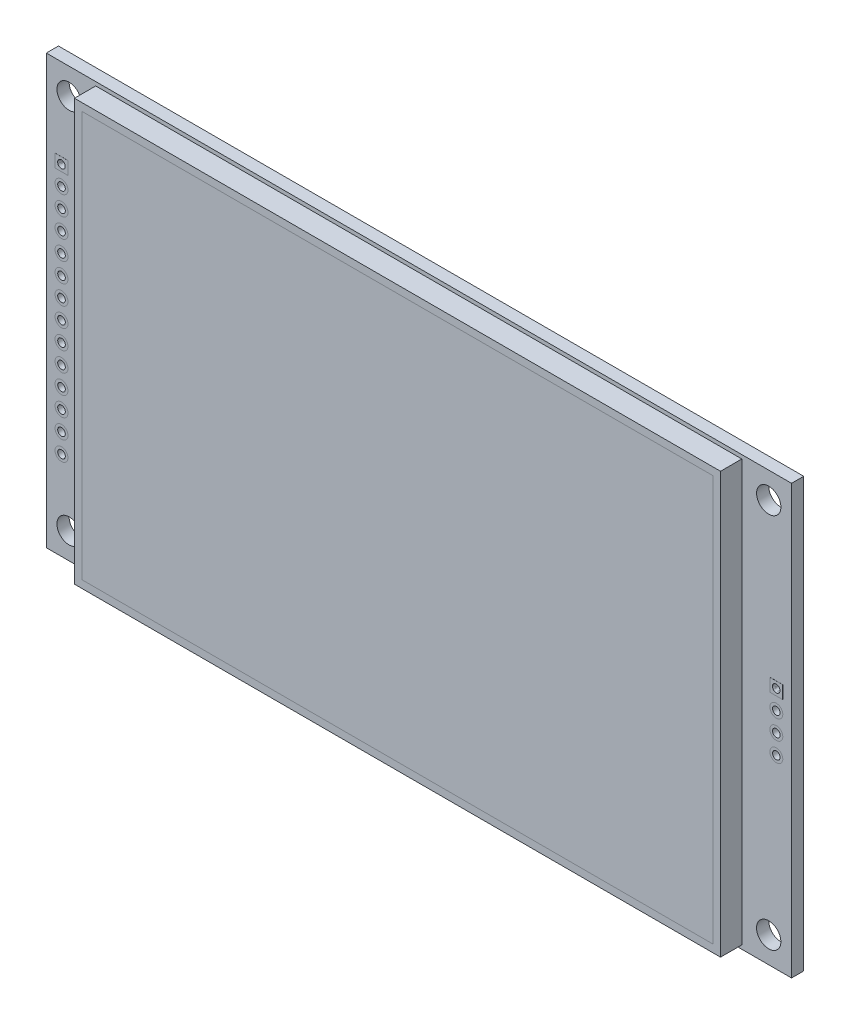
from build123d import *

# Parameters (mm, degrees)
SKETCH2_W               = 98
SKETCH2_H               = 56.34
BOSS_EXTRUDE1_DEPTH     = 0.8
SKETCH3_R               = 1.6
CUT_EXTRUDE1_DEPTH      = 2.6
MIRROR2_COPY_1_SKETCH_R = 1.6
MIRROR2_COPY_1_DEPTH    = 2.6
SKETCH5_W               = 84.96
SKETCH5_H               = 55.34
SKETCH5_W_2             = 82.96
SKETCH5_H_2             = 53.34
BOSS_EXTRUDE2_DEPTH     = 2.8
SKETCH6_W               = 82.96
SKETCH6_H               = 53.34
BOSS_EXTRUDE3_DEPTH     = 2.8
SKETCH9_R               = 0.85
CUT_EXTRUDE2_DEPTH      = 2.6
SKETCH10_R              = 0.85
SKETCH10_R_2            = 0.5
BOSS_EXTRUDE4_DEPTH     = 1.6
BOSS_EXTRUDE4_2_DEPTH   = 1.6
BOSS_EXTRUDE4_3_DEPTH   = 1.6
BOSS_EXTRUDE4_4_DEPTH   = 1.6
BOSS_EXTRUDE4_5_DEPTH   = 1.6
BOSS_EXTRUDE4_6_DEPTH   = 1.6
BOSS_EXTRUDE4_7_DEPTH   = 1.6
BOSS_EXTRUDE4_8_DEPTH   = 1.6
BOSS_EXTRUDE4_9_DEPTH   = 1.6
BOSS_EXTRUDE4_10_DEPTH  = 1.6
BOSS_EXTRUDE4_11_DEPTH  = 1.6
BOSS_EXTRUDE4_12_DEPTH  = 1.6
BOSS_EXTRUDE4_13_DEPTH  = 1.6
BOSS_EXTRUDE4_14_DEPTH  = 1.6
SKETCH11_R              = 0.85
CUT_EXTRUDE3_DEPTH      = 2.6
SKETCH12_R              = 0.85
SKETCH12_R_2            = 0.5
BOSS_EXTRUDE5_DEPTH     = 1.6
BOSS_EXTRUDE5_2_DEPTH   = 1.6
BOSS_EXTRUDE5_3_DEPTH   = 1.6
BOSS_EXTRUDE5_4_DEPTH   = 1.6
BOSS_EXTRUDE7_START     = -0.8
SKETCH13_W              = 1.7
SKETCH13_H              = 1.7
SKETCH13_R              = 0.5
BOSS_EXTRUDE7_DEPTH     = 0.81
BOSS_EXTRUDE8_START     = -0.8
SKETCH15_W              = 1.7
SKETCH15_H              = 1.7
SKETCH15_R              = 0.5
BOSS_EXTRUDE8_DEPTH     = 0.81


with BuildPart() as part:
    # Sketch2 → Boss-Extrude1 (new body, symmetric)
    with BuildSketch(Plane.XY):
        Rectangle(SKETCH2_W, SKETCH2_H)
    extrude(amount=BOSS_EXTRUDE1_DEPTH, both=True)

    # Sketch3 → Cut-Extrude1 (cut, through all)
    with BuildSketch(Plane.XY.offset(0.8)):
        with Locations((-46, 24.75)):
            Circle(SKETCH3_R)
    cut_extrude1 = extrude(amount=-CUT_EXTRUDE1_DEPTH, mode=Mode.SUBTRACT)

    # Mirror1: Cut-Extrude1 across plane
    add(cut_extrude1.mirror(Plane(origin=(0, 0, 0), x_dir=(0, 0, 1), z_dir=(1, 0, 0))), mode=Mode.SUBTRACT)

    # Mirror2: Cut-Extrude1 across plane
    add(cut_extrude1.mirror(Plane.ZX), mode=Mode.SUBTRACT)

    # Mirror2 copy 1 sketch → Mirror2 copy 1 (cut, through all)
    with BuildSketch(Plane(origin=(0, 0, 0.8), x_dir=(-1, 0, 0), z_dir=(0, 0, 1))):
        with Locations((-46, 24.75)):
            Circle(MIRROR2_COPY_1_SKETCH_R)
    extrude(amount=-MIRROR2_COPY_1_DEPTH, mode=Mode.SUBTRACT)

    # Sketch5 → Boss-Extrude2 (add)
    with BuildSketch(Plane.XY.offset(0.8)):
        with Locations((-0.02, 0)):
            Rectangle(SKETCH5_W, SKETCH5_H)
        with Locations((-0.02, 0)):
            Rectangle(SKETCH5_W_2, SKETCH5_H_2, mode=Mode.SUBTRACT)
    extrude(amount=BOSS_EXTRUDE2_DEPTH)

    # Sketch9 → Cut-Extrude2 (cut, through all)
    with BuildSketch(Plane.XY.offset(0.8)):
        with Locations((-47, 16.51)):
            Circle(SKETCH9_R)
        with Locations((-47, 13.97)):
            Circle(SKETCH9_R)
        with Locations((-47, 11.43)):
            Circle(SKETCH9_R)
        with Locations((-47, 8.89)):
            Circle(SKETCH9_R)
        with Locations((-47, 6.35)):
            Circle(SKETCH9_R)
        with Locations((-47, 3.81)):
            Circle(SKETCH9_R)
        with Locations((-47, 1.27)):
            Circle(SKETCH9_R)
        with Locations((-47, -1.27)):
            Circle(SKETCH9_R)
        with Locations((-47, -3.81)):
            Circle(SKETCH9_R)
        with Locations((-47, -6.35)):
            Circle(SKETCH9_R)
        with Locations((-47, -8.89)):
            Circle(SKETCH9_R)
        with Locations((-47, -11.43)):
            Circle(SKETCH9_R)
        with Locations((-47, -13.97)):
            Circle(SKETCH9_R)
        with Locations((-47, -16.51)):
            Circle(SKETCH9_R)
    extrude(amount=-CUT_EXTRUDE2_DEPTH, mode=Mode.SUBTRACT)

    # Sketch11 → Cut-Extrude3 (cut, through all)
    with BuildSketch(Plane.XY.offset(0.8)):
        with Locations((47, 3.81)):
            Circle(SKETCH11_R)
        with Locations((47, 1.27)):
            Circle(SKETCH11_R)
        with Locations((47, -1.27)):
            Circle(SKETCH11_R)
        with Locations((47, -3.81)):
            Circle(SKETCH11_R)
    extrude(amount=-CUT_EXTRUDE3_DEPTH, mode=Mode.SUBTRACT)


with BuildPart() as body_2:
    # Sketch6 → Boss-Extrude3 (new body)
    with BuildSketch(Plane.XY.offset(0.8)):
        with Locations((-0.02, 0)):
            Rectangle(SKETCH6_W, SKETCH6_H)
    extrude(amount=BOSS_EXTRUDE3_DEPTH)


with BuildPart() as body_3:
    # Sketch10 → Boss-Extrude4 (new body)
    with BuildSketch(Plane.XY.offset(0.8)):
        with Locations((-47, 16.51)):
            Circle(SKETCH10_R)
        with Locations((-47, 16.51)):
            Circle(SKETCH10_R_2, mode=Mode.SUBTRACT)
    extrude(amount=-BOSS_EXTRUDE4_DEPTH)


with BuildPart() as body_4:
    # Sketch10 → Boss-Extrude4 2 (new body)
    with BuildSketch(Plane.XY.offset(0.8)):
        with Locations((-47, 13.97)):
            Circle(SKETCH10_R)
        with Locations((-47, 13.97)):
            Circle(SKETCH10_R_2, mode=Mode.SUBTRACT)
    extrude(amount=-BOSS_EXTRUDE4_2_DEPTH)


with BuildPart() as body_5:
    # Sketch10 → Boss-Extrude4 3 (new body)
    with BuildSketch(Plane.XY.offset(0.8)):
        with Locations((-47, 11.43)):
            Circle(SKETCH10_R)
        with Locations((-47, 11.43)):
            Circle(SKETCH10_R_2, mode=Mode.SUBTRACT)
    extrude(amount=-BOSS_EXTRUDE4_3_DEPTH)


with BuildPart() as body_6:
    # Sketch10 → Boss-Extrude4 4 (new body)
    with BuildSketch(Plane.XY.offset(0.8)):
        with Locations((-47, 8.89)):
            Circle(SKETCH10_R)
        with Locations((-47, 8.89)):
            Circle(SKETCH10_R_2, mode=Mode.SUBTRACT)
    extrude(amount=-BOSS_EXTRUDE4_4_DEPTH)


with BuildPart() as body_7:
    # Sketch10 → Boss-Extrude4 5 (new body)
    with BuildSketch(Plane.XY.offset(0.8)):
        with Locations((-47, 6.35)):
            Circle(SKETCH10_R)
        with Locations((-47, 6.35)):
            Circle(SKETCH10_R_2, mode=Mode.SUBTRACT)
    extrude(amount=-BOSS_EXTRUDE4_5_DEPTH)


with BuildPart() as body_8:
    # Sketch10 → Boss-Extrude4 6 (new body)
    with BuildSketch(Plane.XY.offset(0.8)):
        with Locations((-47, 3.81)):
            Circle(SKETCH10_R)
        with Locations((-47, 3.81)):
            Circle(SKETCH10_R_2, mode=Mode.SUBTRACT)
    extrude(amount=-BOSS_EXTRUDE4_6_DEPTH)


with BuildPart() as body_9:
    # Sketch10 → Boss-Extrude4 7 (new body)
    with BuildSketch(Plane.XY.offset(0.8)):
        with Locations((-47, 1.27)):
            Circle(SKETCH10_R)
        with Locations((-47, 1.27)):
            Circle(SKETCH10_R_2, mode=Mode.SUBTRACT)
    extrude(amount=-BOSS_EXTRUDE4_7_DEPTH)


with BuildPart() as body_10:
    # Sketch10 → Boss-Extrude4 8 (new body)
    with BuildSketch(Plane.XY.offset(0.8)):
        with Locations((-47, -1.27)):
            Circle(SKETCH10_R)
        with Locations((-47, -1.27)):
            Circle(SKETCH10_R_2, mode=Mode.SUBTRACT)
    extrude(amount=-BOSS_EXTRUDE4_8_DEPTH)


with BuildPart() as body_11:
    # Sketch10 → Boss-Extrude4 9 (new body)
    with BuildSketch(Plane.XY.offset(0.8)):
        with Locations((-47, -3.81)):
            Circle(SKETCH10_R)
        with Locations((-47, -3.81)):
            Circle(SKETCH10_R_2, mode=Mode.SUBTRACT)
    extrude(amount=-BOSS_EXTRUDE4_9_DEPTH)


with BuildPart() as body_12:
    # Sketch10 → Boss-Extrude4 10 (new body)
    with BuildSketch(Plane.XY.offset(0.8)):
        with Locations((-47, -6.35)):
            Circle(SKETCH10_R)
        with Locations((-47, -6.35)):
            Circle(SKETCH10_R_2, mode=Mode.SUBTRACT)
    extrude(amount=-BOSS_EXTRUDE4_10_DEPTH)


with BuildPart() as body_13:
    # Sketch10 → Boss-Extrude4 11 (new body)
    with BuildSketch(Plane.XY.offset(0.8)):
        with Locations((-47, -8.89)):
            Circle(SKETCH10_R)
        with Locations((-47, -8.89)):
            Circle(SKETCH10_R_2, mode=Mode.SUBTRACT)
    extrude(amount=-BOSS_EXTRUDE4_11_DEPTH)


with BuildPart() as body_14:
    # Sketch10 → Boss-Extrude4 12 (new body)
    with BuildSketch(Plane.XY.offset(0.8)):
        with Locations((-47, -11.43)):
            Circle(SKETCH10_R)
        with Locations((-47, -11.43)):
            Circle(SKETCH10_R_2, mode=Mode.SUBTRACT)
    extrude(amount=-BOSS_EXTRUDE4_12_DEPTH)


with BuildPart() as body_15:
    # Sketch10 → Boss-Extrude4 13 (new body)
    with BuildSketch(Plane.XY.offset(0.8)):
        with Locations((-47, -13.97)):
            Circle(SKETCH10_R)
        with Locations((-47, -13.97)):
            Circle(SKETCH10_R_2, mode=Mode.SUBTRACT)
    extrude(amount=-BOSS_EXTRUDE4_13_DEPTH)


with BuildPart() as body_16:
    # Sketch10 → Boss-Extrude4 14 (new body)
    with BuildSketch(Plane.XY.offset(0.8)):
        with Locations((-47, -16.51)):
            Circle(SKETCH10_R)
        with Locations((-47, -16.51)):
            Circle(SKETCH10_R_2, mode=Mode.SUBTRACT)
    extrude(amount=-BOSS_EXTRUDE4_14_DEPTH)


with BuildPart() as body_17:
    # Sketch12 → Boss-Extrude5 (new body)
    with BuildSketch(Plane.XY.offset(0.8)):
        with Locations((47, 3.81)):
            Circle(SKETCH12_R)
        with Locations((47, 3.81)):
            Circle(SKETCH12_R_2, mode=Mode.SUBTRACT)
    extrude(amount=-BOSS_EXTRUDE5_DEPTH)


with BuildPart() as body_18:
    # Sketch12 → Boss-Extrude5 2 (new body)
    with BuildSketch(Plane.XY.offset(0.8)):
        with Locations((47, 1.27)):
            Circle(SKETCH12_R)
        with Locations((47, 1.27)):
            Circle(SKETCH12_R_2, mode=Mode.SUBTRACT)
    extrude(amount=-BOSS_EXTRUDE5_2_DEPTH)


with BuildPart() as body_19:
    # Sketch12 → Boss-Extrude5 3 (new body)
    with BuildSketch(Plane.XY.offset(0.8)):
        with Locations((47, -1.27)):
            Circle(SKETCH12_R)
        with Locations((47, -1.27)):
            Circle(SKETCH12_R_2, mode=Mode.SUBTRACT)
    extrude(amount=-BOSS_EXTRUDE5_3_DEPTH)


with BuildPart() as body_20:
    # Sketch12 → Boss-Extrude5 4 (new body)
    with BuildSketch(Plane.XY.offset(0.8)):
        with Locations((47, -3.81)):
            Circle(SKETCH12_R)
        with Locations((47, -3.81)):
            Circle(SKETCH12_R_2, mode=Mode.SUBTRACT)
    extrude(amount=-BOSS_EXTRUDE5_4_DEPTH)


with BuildPart() as body_21:
    # Sketch13 → Boss-Extrude7 (new body, symmetric)
    with BuildSketch(Plane.XY.offset(0.8).offset(BOSS_EXTRUDE7_START)):
        with Locations((-47, 16.51)):
            Rectangle(SKETCH13_W, SKETCH13_H)
        with Locations((-47, 16.51)):
            Circle(SKETCH13_R, mode=Mode.SUBTRACT)
    extrude(amount=BOSS_EXTRUDE7_DEPTH, both=True)


with BuildPart() as body_22:
    # Sketch15 → Boss-Extrude8 (new body, symmetric)
    with BuildSketch(Plane.XY.offset(0.8).offset(BOSS_EXTRUDE8_START)):
        with Locations((47, 3.81)):
            Rectangle(SKETCH15_W, SKETCH15_H)
        with Locations((47, 3.81)):
            Circle(SKETCH15_R, mode=Mode.SUBTRACT)
    extrude(amount=BOSS_EXTRUDE8_DEPTH, both=True)


solid = Compound([part.part, body_2.part, body_3.part, body_4.part, body_5.part, body_6.part, body_7.part, body_8.part, body_9.part, body_10.part, body_11.part, body_12.part, body_13.part, body_14.part, body_15.part, body_16.part, body_17.part, body_18.part, body_19.part, body_20.part, body_21.part, body_22.part])
